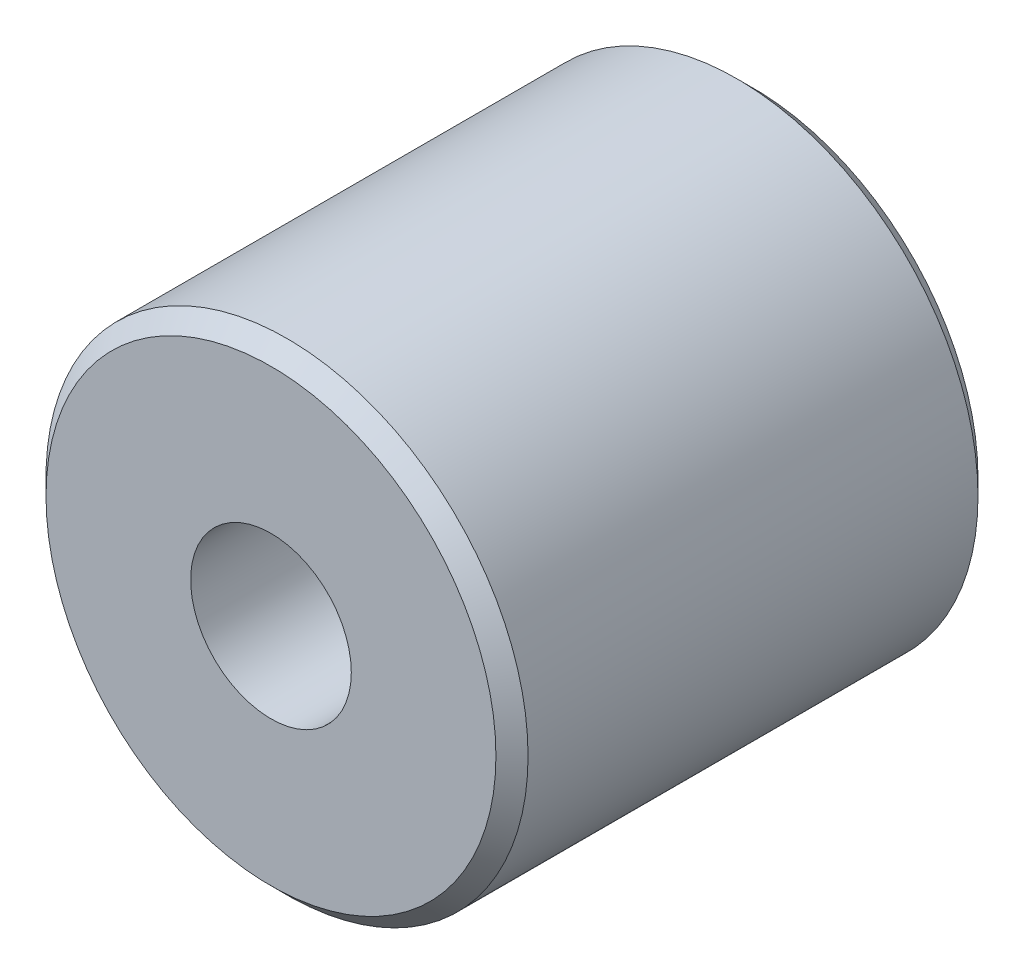
from build123d import *

# Parameters (mm, degrees)
SKETCH1_R           = 15
SKETCH1_R_2         = 5
BOSS_EXTRUDE1_DEPTH = 30
CHAMFER1_SIZE       = 1


with BuildPart() as part:
    # Sketch1 → Boss-Extrude1 (new body)
    with BuildSketch(Plane.XY):
        Circle(SKETCH1_R)
        Circle(SKETCH1_R_2, mode=Mode.SUBTRACT)
    extrude(amount=BOSS_EXTRUDE1_DEPTH)

    # Chamfer1
    chamfer1_edges = [part.edges().sort_by_distance(p)[0] for p in [
        (-15, 0, 0),
        (-15, 0, 30),
    ]]
    chamfer(chamfer1_edges, length=CHAMFER1_SIZE)


solid = part.part
